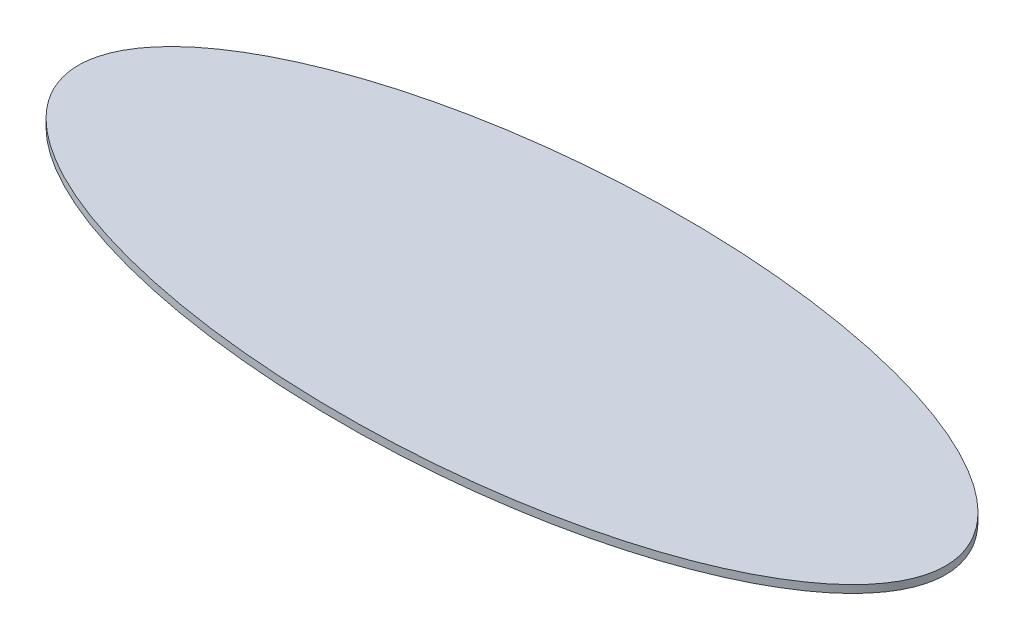
from build123d import *

# Parameters (mm, degrees)
SKETCH1_RX          = 28.215
SKETCH1_RY          = 11.11
BOSS_EXTRUDE1_DEPTH = 0.5


with BuildPart() as part:
    # Sketch1 → Boss-Extrude1 (new body)
    with BuildSketch(Plane(origin=(0, 0, 0), x_dir=(1, 0, 0), z_dir=(0, 1, 0))):
        with Locations(Location((0, 0), (0, 0, 0))):
            Ellipse(SKETCH1_RX, SKETCH1_RY)
    extrude(amount=BOSS_EXTRUDE1_DEPTH)


solid = part.part
